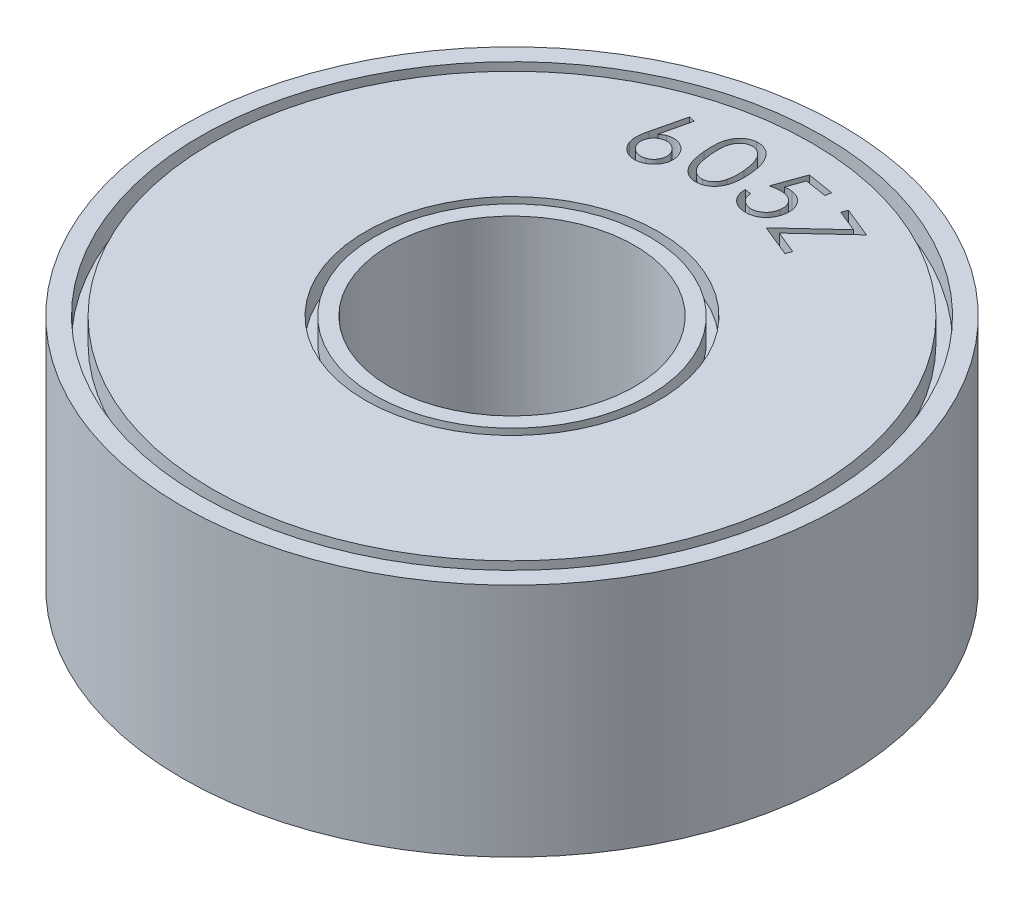
from build123d import *

# Parameters (mm, degrees)
SKETCH1_R           = 7
SKETCH1_R_2         = 2.6
BOSS_EXTRUDE1_DEPTH = 5
SKETCH2_R           = 3.107412226
SKETCH2_R_2         = 2.917242266
CUT_EXTRUDE1_DEPTH  = 0.5
SKETCH3_R           = 6.614287506
SKETCH3_R_2         = 6.365008751
CUT_EXTRUDE2_DEPTH  = 0.5
CUT_EXTRUDE3_DEPTH  = 0.5
SKETCH7_R           = 6.648627536
SKETCH7_R_2         = 6.469556806
SKETCH7_R_3         = 3.047068381
SKETCH7_R_4         = 2.824964769
CUT_EXTRUDE4_DEPTH  = 0.5
CUT_EXTRUDE5_DEPTH  = 0.5


with BuildPart() as part:
    # Sketch1 → Boss-Extrude1 (new body)
    with BuildSketch(Plane(origin=(0, 0, 0), x_dir=(1, 0, 0), z_dir=(0, 1, 0))):
        with Locations(Location((0, 0, 0), (0, 0, 270))):
            Circle(SKETCH1_R)
        with Locations(Location((0, 0, 0), (0, 0, 270))):
            Circle(SKETCH1_R_2, mode=Mode.SUBTRACT)
    extrude(amount=BOSS_EXTRUDE1_DEPTH)

    # Sketch2 → Cut-Extrude1 (cut)
    with BuildSketch(Plane(origin=(0, 5, 0), x_dir=(1, 0, 0), z_dir=(0, 1, 0))):
        with Locations(Location((0, 0, 0), (0, 0, 270))):
            Circle(SKETCH2_R)
        with Locations(Location((0, 0, 0), (0, 0, 270))):
            Circle(SKETCH2_R_2, mode=Mode.SUBTRACT)
    extrude(amount=-CUT_EXTRUDE1_DEPTH, mode=Mode.SUBTRACT)

    # Sketch3 → Cut-Extrude2 (cut)
    with BuildSketch(Plane(origin=(0, 5, 0), x_dir=(1, 0, 0), z_dir=(0, 1, 0))):
        with Locations(Location((0, 0, 0), (0, 0, 270))):
            Circle(SKETCH3_R)
        with Locations(Location((0, 0, 0), (0, 0, 270))):
            Circle(SKETCH3_R_2, mode=Mode.SUBTRACT)
    extrude(amount=-CUT_EXTRUDE2_DEPTH, mode=Mode.SUBTRACT)

    # Sketch5 → Cut-Extrude3 (cut)
    with BuildSketch(Plane(origin=(0, 5, 0), x_dir=(1, 0, 0), z_dir=(0, 1, 0))):
        with BuildLine():
            Line((-1.77464756, 5.546064141), (-1.648769071, 5.517178341))
            Line((-1.648769071, 5.517178341), (-1.794788118, 4.890965984))
            add(Edge.make_bspline(
                [(-1.794788118, 4.890965984), (-1.785096073, 4.898458099), (-1.766189956, 4.913072848), (-1.736665853, 4.931761196), (-1.707427507, 4.947854783), (-1.687285201, 4.9559104), (-1.677389864, 4.959867894)],
                knots=[0, 0, 0, 0, 1.074983439, 2.096953016, 3.065087646, 4, 4, 4, 4], degree=3))
            add(Edge.make_bspline(
                [(-1.677389864, 4.959867894), (-1.665275584, 4.964019421), (-1.641449235, 4.972184638), (-1.604872801, 4.979723444), (-1.568588417, 4.983796753), (-1.532418517, 4.984158001), (-1.496378982, 4.980279861), (-1.460457571, 4.972930764), (-1.424834929, 4.961338909), (-1.389812824, 4.946313678), (-1.356125763, 4.928119279), (-1.324370957, 4.907327131), (-1.295679138, 4.883129899), (-1.269261033, 4.856721626), (-1.24590325, 4.8272106), (-1.224814398, 4.795293225), (-1.206433444, 4.760488564), (-1.196617452, 4.735771442), (-1.191631401, 4.723216335)],
                knots=[0, 0, 0, 0, 1.020154289, 2.006438123, 2.970106571, 3.927992439, 4.883908413, 5.854961009, 6.846136469, 7.86526912, 8.889427122, 9.895430617, 10.885579588, 11.87665495, 12.868805842, 13.880684614, 14.923489853, 16, 16, 16, 16], degree=3))
            add(Edge.make_bspline(
                [(-1.191631401, 4.723216335), (-1.185763997, 4.705677489), (-1.174231565, 4.671204739), (-1.16536594, 4.617909511), (-1.163378909, 4.564984654), (-1.168718636, 4.51273181), (-1.180965661, 4.461942206), (-1.199840731, 4.41310195), (-1.226271738, 4.367045113), (-1.258666864, 4.32379223), (-1.29660493, 4.28474739), (-1.339171993, 4.251149774), (-1.385599916, 4.22271722), (-1.419232295, 4.208920841), (-1.43623318, 4.201946887)],
                knots=[0, 0, 0, 0, 1.035512558, 2.035308643, 3.016484276, 3.997109838, 4.970052175, 5.937534324, 6.922203205, 7.93743261, 8.960063542, 9.96475378, 10.971200086, 12, 12, 12, 12], degree=3))
            add(Edge.make_bspline(
                [(-1.43623318, 4.201946887), (-1.453069731, 4.196349022), (-1.486328625, 4.18529101), (-1.538132233, 4.177075568), (-1.590209072, 4.17507396), (-1.642272632, 4.180121209), (-1.693185104, 4.19200707), (-1.741823995, 4.210665009), (-1.78756302, 4.236127091), (-1.829741861, 4.267944116), (-1.867829416, 4.304857265), (-1.900548991, 4.346263197), (-1.928197584, 4.391352218), (-1.941510188, 4.423986908), (-1.948227371, 4.440453498)],
                knots=[0, 0, 0, 0, 1.013740106, 2.002540567, 2.98876705, 3.989087606, 4.985813625, 5.971392323, 6.960102356, 7.970965595, 8.986065581, 9.986181813, 10.983881298, 12, 12, 12, 12], degree=3))
            add(Edge.make_bspline(
                [(-1.948227371, 4.440453498), (-1.952555425, 4.45336504), (-1.961336427, 4.479560707), (-1.96978437, 4.521095857), (-1.975460254, 4.564748639), (-1.976913266, 4.602895327), (-1.97619598, 4.635077867), (-1.974566121, 4.661151722), (-1.971961923, 4.688923168), (-1.9678103, 4.718128126), (-1.963147279, 4.749098068), (-1.957025936, 4.781619659), (-1.949483101, 4.815748189), (-1.944095701, 4.839029234), (-1.94133718, 4.850949875)],
                knots=[0, 0, 0, 0, 1.175268312, 2.384450834, 3.653583733, 4.974682368, 5.67682338, 6.433595722, 7.230792766, 8.085439344, 8.981130992, 9.935908238, 10.943118889, 12, 12, 12, 12], degree=3))
            Line((-1.94133718, 4.850949875), (-1.77464756, 5.546064141))
        make_face()
        with BuildLine():
            add(Edge.make_bspline(
                [(-1.66678957, 4.841144603), (-1.675432998, 4.837689072), (-1.692559368, 4.83084217), (-1.716598923, 4.81781237), (-1.738850711, 4.802791065), (-1.759373562, 4.785926814), (-1.777627034, 4.766544045), (-1.794474921, 4.745711209), (-1.809064257, 4.722566186), (-1.821932712, 4.697974042), (-1.832525016, 4.672270155), (-1.840114084, 4.64601945), (-1.84577111, 4.619746751), (-1.847555861, 4.59313258), (-1.847552339, 4.566500973), (-1.844144539, 4.539801039), (-1.838408479, 4.5128864), (-1.832505281, 4.495260711), (-1.82950408, 4.486299768)],
                knots=[0, 0, 0, 0, 1.028577375, 2.038056822, 3.015999467, 3.993942112, 4.967974926, 5.954899733, 6.95197029, 7.987342216, 9.021192721, 10.019410766, 11.005900495, 11.985743526, 12.962514865, 13.946244635, 14.955865826, 16, 16, 16, 16], degree=3))
            add(Edge.make_bspline(
                [(-1.82950408, 4.486299768), (-1.826048549, 4.477656341), (-1.819201647, 4.460529971), (-1.806171847, 4.436490416), (-1.791150541, 4.414238628), (-1.774286291, 4.393715776), (-1.754903522, 4.375462306), (-1.734070687, 4.358614411), (-1.710925662, 4.344025106), (-1.686333522, 4.331156531), (-1.660629623, 4.320564671), (-1.634378961, 4.312974009), (-1.608192387, 4.307341368), (-1.581669454, 4.30552229), (-1.555126027, 4.305543969), (-1.528508398, 4.308917039), (-1.501773254, 4.314685766), (-1.484326544, 4.32058519), (-1.475454267, 4.323585258)],
                knots=[0, 0, 0, 0, 1.030418755, 2.041705391, 3.021398769, 4.001092146, 4.976868692, 5.965560311, 6.964415844, 8.001641312, 9.037342637, 10.037347711, 11.025603474, 11.997447403, 12.975967378, 13.96145824, 14.963328506, 16, 16, 16, 16], degree=3))
            add(Edge.make_bspline(
                [(-1.475454267, 4.323585258), (-1.466705766, 4.32700987), (-1.449518125, 4.333737995), (-1.425590086, 4.347107914), (-1.403132662, 4.361720393), (-1.38299218, 4.37902272), (-1.364193363, 4.397707948), (-1.347887476, 4.418969603), (-1.332787338, 4.441715771), (-1.320401516, 4.466587551), (-1.30964518, 4.492251698), (-1.302146693, 4.518637162), (-1.296609509, 4.544909262), (-1.294221462, 4.571407636), (-1.294821472, 4.597962542), (-1.298038022, 4.624580792), (-1.303849043, 4.651316123), (-1.309742648, 4.668762808), (-1.312739757, 4.677635071)],
                knots=[0, 0, 0, 0, 1.039051435, 2.041360351, 3.028812302, 4.000639027, 4.975856113, 5.958111039, 6.961898324, 7.994252835, 9.02956857, 10.038584196, 11.026472033, 11.998790847, 12.977093218, 13.962217185, 14.963714457, 16, 16, 16, 16], degree=3))
            add(Edge.make_bspline(
                [(-1.312739757, 4.677635071), (-1.316179921, 4.686374706), (-1.322967077, 4.703617273), (-1.336165659, 4.727734109), (-1.350984461, 4.750218571), (-1.368075105, 4.770714672), (-1.387139748, 4.789326121), (-1.408371857, 4.805749132), (-1.431140547, 4.820825574), (-1.456003858, 4.833225871), (-1.481600274, 4.843916135), (-1.507866672, 4.851519868), (-1.53406513, 4.856995741), (-1.56056444, 4.859424893), (-1.587096227, 4.858703179), (-1.613756326, 4.855941614), (-1.6404677, 4.850009787), (-1.657916321, 4.844133106), (-1.66678957, 4.841144603)],
                knots=[0, 0, 0, 0, 1.038234345, 2.048349523, 3.035024961, 4.013583476, 4.995017316, 5.976499817, 6.979497743, 8.011040432, 9.045542016, 10.044388699, 11.031499681, 12.003053883, 12.980586937, 13.963819656, 14.964529371, 16, 16, 16, 16], degree=3))
        make_face(mode=Mode.SUBTRACT)
        with BuildLine():
            add(Edge.make_bspline(
                [(-0.986592206, 5.067066278), (-0.988405517, 5.08816878), (-0.991922584, 5.129098826), (-0.994830361, 5.18893886), (-0.99568949, 5.245242381), (-0.994482554, 5.298033199), (-0.990960664, 5.347180076), (-0.985962819, 5.39289328), (-0.978134053, 5.435054616), (-0.968798981, 5.474096316), (-0.956721509, 5.510083321), (-0.944001545, 5.544150393), (-0.929077602, 5.575979261), (-0.912561462, 5.6057805), (-0.894659432, 5.633779016), (-0.874576009, 5.659392902), (-0.853464208, 5.683518684), (-0.830332972, 5.70516311), (-0.805956552, 5.72467695), (-0.780783746, 5.74238274), (-0.754415082, 5.757386548), (-0.727329931, 5.77057498), (-0.699068392, 5.781128909), (-0.669833797, 5.789593351), (-0.639650584, 5.796117592), (-0.619054064, 5.798398853), (-0.608691732, 5.79954658)],
                knots=[0, 0, 0, 0, 1.644809883, 3.190244655, 4.651655908, 6.017307418, 7.28961207, 8.477552208, 9.586351613, 10.617970442, 11.592075519, 12.532351563, 13.440830871, 14.319069932, 15.177278937, 16.01845527, 16.844557458, 17.66474179, 18.474734591, 19.268320699, 20.052030048, 20.828347882, 21.605604854, 22.391533073, 23.190762926, 24, 24, 24, 24], degree=3))
            add(Edge.make_bspline(
                [(-0.608691732, 5.79954658), (-0.598187027, 5.800323587), (-0.577282375, 5.801869852), (-0.54606043, 5.801366106), (-0.515357616, 5.797989189), (-0.485191239, 5.79285449), (-0.455610185, 5.785056332), (-0.426500698, 5.774972801), (-0.39806028, 5.762190102), (-0.370087092, 5.747358303), (-0.343048552, 5.730098341), (-0.316918719, 5.710427398), (-0.292152609, 5.688130786), (-0.268325707, 5.663592234), (-0.245908844, 5.636451477), (-0.224279608, 5.607026803), (-0.204375327, 5.57484862), (-0.185039179, 5.540523718), (-0.167201701, 5.50322229), (-0.151090504, 5.462559348), (-0.136657363, 5.418626589), (-0.123602991, 5.371415898), (-0.112247787, 5.320922779), (-0.102913564, 5.266929577), (-0.094561085, 5.209774182), (-0.090541955, 5.170437199), (-0.088482313, 5.150278585)],
                knots=[0, 0, 0, 0, 0.812180823, 1.616262325, 2.404042693, 3.19261816, 3.974275905, 4.760758835, 5.565994135, 6.376773437, 7.200841365, 8.037515538, 8.89642022, 9.768545579, 10.673172549, 11.609396373, 12.582931568, 13.589475693, 14.646938443, 15.769165122, 16.960630792, 18.211937759, 19.545843377, 20.95051789, 22.437263645, 24, 24, 24, 24], degree=3))
            add(Edge.make_bspline(
                [(-0.088482313, 5.150278585), (-0.086718711, 5.130149191), (-0.083280361, 5.090904566), (-0.081150173, 5.033430578), (-0.080327749, 4.978893982), (-0.082231683, 4.927340193), (-0.086129592, 4.878784806), (-0.092113531, 4.83318633), (-0.100600815, 4.790646402), (-0.110997939, 4.750840701), (-0.123086248, 4.713611329), (-0.137404835, 4.67883355), (-0.15246791, 4.645836287), (-0.169946919, 4.615261347), (-0.188684085, 4.586587823), (-0.209040003, 4.55999301), (-0.231279282, 4.535789537), (-0.254701569, 4.51347301), (-0.2797379, 4.493742672), (-0.305418064, 4.475749664), (-0.332323281, 4.460494027), (-0.360000466, 4.446981602), (-0.388803989, 4.436266038), (-0.418492042, 4.427737442), (-0.449046196, 4.421268089), (-0.469891665, 4.418787241), (-0.480428177, 4.417533275)],
                knots=[0, 0, 0, 0, 1.560019437, 3.041441778, 4.439806569, 5.770751862, 7.023175031, 8.200063667, 9.319720786, 10.37028258, 11.375444132, 12.3393508, 13.27310108, 14.174140243, 15.055735392, 15.916610614, 16.75672562, 17.591479347, 18.411727224, 19.215849523, 20.010279916, 20.797385231, 21.591727773, 22.379689713, 23.181000944, 24, 24, 24, 24], degree=3))
            add(Edge.make_bspline(
                [(-0.480428177, 4.417533275), (-0.490846105, 4.416715793), (-0.511490833, 4.415095826), (-0.542241203, 4.416173667), (-0.572466097, 4.418946021), (-0.60202656, 4.424352311), (-0.6311886, 4.431639762), (-0.659514019, 4.441929323), (-0.687485449, 4.454070877), (-0.714774614, 4.468696931), (-0.741288509, 4.485562588), (-0.766436515, 4.50503044), (-0.790555232, 4.526626331), (-0.813192587, 4.55083673), (-0.835038518, 4.577153355), (-0.855722282, 4.605802764), (-0.875066191, 4.636902629), (-0.893205614, 4.670621463), (-0.910258882, 4.707248002), (-0.925653379, 4.747535897), (-0.939312148, 4.791669775), (-0.95162656, 4.839543346), (-0.962835528, 4.891055097), (-0.972205553, 4.946348682), (-0.980536776, 5.005364331), (-0.984535848, 5.046112966), (-0.986592206, 5.067066278)],
                knots=[0, 0, 0, 0, 0.811819082, 1.608744364, 2.388468332, 3.16982384, 3.942712656, 4.722527355, 5.509806294, 6.311717109, 7.127101459, 7.949913989, 8.781479029, 9.641374982, 10.524221401, 11.439154072, 12.386256276, 13.369568315, 14.41427916, 15.525178722, 16.719851279, 18.004138739, 19.367348028, 20.817077663, 22.363312919, 24, 24, 24, 24], degree=3))
        make_face()
        with BuildLine():
            add(Edge.make_bspline(
                [(-0.861773746, 5.076076528), (-0.860034501, 5.058042856), (-0.856669996, 5.023157399), (-0.849898353, 4.97272846), (-0.842656906, 4.925756881), (-0.834137475, 4.882380695), (-0.825006669, 4.842447212), (-0.814608295, 4.806142032), (-0.803679419, 4.773116456), (-0.791256022, 4.743503106), (-0.778349902, 4.716357346), (-0.763772911, 4.69172033), (-0.748818833, 4.668536566), (-0.732589575, 4.647290825), (-0.715372738, 4.627822882), (-0.696930897, 4.610412953), (-0.677958666, 4.594188695), (-0.650961225, 4.576396311), (-0.616638646, 4.557633897), (-0.573699282, 4.543092131), (-0.530375994, 4.53484129), (-0.501482035, 4.536138698), (-0.48705336, 4.536786581)],
                knots=[0, 0, 0, 0, 1.481038001, 2.865012089, 4.15917067, 5.365885815, 6.478258119, 7.506956557, 8.452436816, 9.320168659, 10.130881019, 10.907521234, 11.658660638, 12.385199366, 13.091093666, 13.780655211, 14.457506438, 15.128514792, 16.420798057, 17.642653434, 18.822820111, 20, 20, 20, 20], degree=3))
            add(Edge.make_bspline(
                [(-0.48705336, 4.536786581), (-0.472716343, 4.538849284), (-0.444130437, 4.542962012), (-0.40294404, 4.55819322), (-0.363896239, 4.580111116), (-0.333936262, 4.604177068), (-0.311485928, 4.626547887), (-0.295627577, 4.645285823), (-0.281187577, 4.665877724), (-0.268433816, 4.688214011), (-0.256128715, 4.711872951), (-0.246160566, 4.737700231), (-0.236611605, 4.76490115), (-0.231876563, 4.783904941), (-0.229466221, 4.793578698)],
                knots=[0, 0, 0, 0, 1.336060631, 2.663908518, 4.03149843, 5.461320918, 6.200520743, 6.959707959, 7.727804488, 8.522029534, 9.336529577, 10.190370498, 11.078819832, 12, 12, 12, 12], degree=3))
            add(Edge.make_bspline(
                [(-0.229466221, 4.793578698), (-0.226579221, 4.805915681), (-0.220713244, 4.830982699), (-0.214572728, 4.869786025), (-0.209777915, 4.910183575), (-0.206571393, 4.952179083), (-0.205371721, 4.995859008), (-0.205577011, 5.041206399), (-0.207739339, 5.088229892), (-0.210373931, 5.120074943), (-0.211710729, 5.136233195)],
                knots=[0, 0, 0, 0, 0.881959968, 1.792018815, 2.733462538, 3.714210099, 4.723398733, 5.775191773, 6.87112714, 8, 8, 8, 8], degree=3))
            add(Edge.make_bspline(
                [(-0.211710729, 5.136233195), (-0.21328037, 5.152410452), (-0.216348531, 5.184031971), (-0.222661172, 5.230099309), (-0.230543888, 5.273692474), (-0.238792266, 5.315055022), (-0.248589929, 5.354062823), (-0.259740382, 5.390645457), (-0.271883939, 5.424893965), (-0.285154987, 5.456831814), (-0.299457725, 5.486433365), (-0.314434828, 5.51393095), (-0.330872715, 5.538789702), (-0.347316728, 5.562056719), (-0.365158586, 5.582710304), (-0.383798868, 5.601218573), (-0.403425055, 5.617297732), (-0.429932661, 5.635884186), (-0.464334579, 5.653883046), (-0.506658757, 5.668951342), (-0.549710806, 5.676208622), (-0.578286758, 5.675043633), (-0.592526284, 5.674463113)],
                knots=[0, 0, 0, 0, 1.329646321, 2.599046225, 3.802658319, 4.95354198, 6.049043318, 7.09153349, 8.081313068, 9.020820353, 9.919410277, 10.770170308, 11.580011283, 12.356297843, 13.099412652, 13.809755219, 14.502829676, 15.172447414, 16.455882401, 17.664949743, 18.836433918, 20, 20, 20, 20], degree=3))
            add(Edge.make_bspline(
                [(-0.592526284, 5.674463113), (-0.606942314, 5.672385418), (-0.635682535, 5.668243264), (-0.677271153, 5.653240073), (-0.716185853, 5.630356002), (-0.746684393, 5.60636804), (-0.769329221, 5.583727392), (-0.785364775, 5.56481347), (-0.799812153, 5.544127106), (-0.813174932, 5.521903261), (-0.825416603, 5.498166619), (-0.835849787, 5.47251684), (-0.845549518, 5.445548513), (-0.853452709, 5.416556329), (-0.860230676, 5.385185521), (-0.865107924, 5.350732891), (-0.868516961, 5.312966123), (-0.87028139, 5.271936874), (-0.870524543, 5.227650019), (-0.869017473, 5.180115416), (-0.866563749, 5.129192417), (-0.863405971, 5.094176114), (-0.861773746, 5.076076528)],
                knots=[0, 0, 0, 0, 1.188628619, 2.369684876, 3.586225843, 4.86646694, 5.530378326, 6.201751162, 6.891065185, 7.590893375, 8.320892274, 9.072022264, 9.853244675, 10.662798496, 11.526895042, 12.475782571, 13.505652775, 14.62626638, 15.83242943, 17.12574396, 18.51432504, 20, 20, 20, 20], degree=3))
        make_face(mode=Mode.SUBTRACT)
        with BuildLine():
            Line((1.125972477, 5.661253546), (1.106361934, 5.537230108))
            Line((1.106361934, 5.537230108), (0.642069065, 5.61090215))
            Line((0.642069065, 5.61090215), (0.520960708, 5.265862587))
            add(Edge.make_bspline(
                [(0.520960708, 5.265862587), (0.535343971, 5.267484323), (0.563170685, 5.270621831), (0.603903619, 5.271782477), (0.64201574, 5.270805066), (0.666377926, 5.267647965), (0.678110064, 5.266127594)],
                knots=[0, 0, 0, 0, 1.101444241, 2.130919383, 3.099903783, 4, 4, 4, 4], degree=3))
            add(Edge.make_bspline(
                [(0.678110064, 5.266127594), (0.69257013, 5.263483678), (0.721004781, 5.258284612), (0.761920056, 5.245969055), (0.800354011, 5.23027565), (0.836306043, 5.211201585), (0.869518595, 5.188506791), (0.900373588, 5.162699718), (0.928125929, 5.132996072), (0.953481423, 5.100586798), (0.975711713, 5.065773304), (0.994109436, 5.029008045), (1.008491645, 4.990635083), (1.018848134, 4.950748306), (1.025119719, 4.909365068), (1.027875013, 4.866528064), (1.026178309, 4.822079024), (1.02224288, 4.792181419), (1.020234546, 4.776924035)],
                knots=[0, 0, 0, 0, 1.053815571, 2.072250396, 3.058335495, 4.027830679, 4.985680291, 5.938991898, 6.907181616, 7.895869278, 8.887294429, 9.86495549, 10.839469665, 11.821556223, 12.815428567, 13.837582294, 14.896472219, 16, 16, 16, 16], degree=3))
            add(Edge.make_bspline(
                [(1.020234546, 4.776924035), (1.018323631, 4.766386501), (1.014527536, 4.745453345), (1.006754128, 4.714768681), (0.997591963, 4.684837405), (0.986086143, 4.656073077), (0.973122764, 4.628178182), (0.958461266, 4.601251976), (0.94207478, 4.57525549), (0.923770232, 4.550498976), (0.904324512, 4.526944531), (0.883499221, 4.505190327), (0.861931833, 4.484934646), (0.838777874, 4.466874503), (0.814943897, 4.450173702), (0.78970821, 4.435508467), (0.76359294, 4.422579487), (0.736430333, 4.411352712), (0.708407477, 4.40219696), (0.679684772, 4.39461789), (0.650240698, 4.389447582), (0.62015434, 4.385952931), (0.589352049, 4.384414186), (0.557842706, 4.384621606), (0.525630248, 4.387053485), (0.504074437, 4.390071648), (0.493134937, 4.391603355)],
                knots=[0, 0, 0, 0, 1.053663813, 2.0931378, 3.113236906, 4.131890297, 5.139203412, 6.138985671, 7.147123746, 8.160831377, 9.167056011, 10.150912663, 11.122867697, 12.075978519, 13.038164913, 13.984950897, 14.94525034, 15.904210948, 16.874648547, 17.844579808, 18.825089279, 19.813926352, 20.823712324, 21.858267034, 22.913077848, 24, 24, 24, 24], degree=3))
            add(Edge.make_bspline(
                [(0.493134937, 4.391603355), (0.480182866, 4.393923545), (0.454728762, 4.398483306), (0.418017431, 4.409368906), (0.383261331, 4.42242937), (0.35057863, 4.438593389), (0.319782682, 4.45722738), (0.291332576, 4.479269847), (0.264742057, 4.503660327), (0.240318063, 4.530642877), (0.218883359, 4.559953095), (0.199810604, 4.590599709), (0.183855182, 4.622699353), (0.171226137, 4.656223269), (0.161192582, 4.690921364), (0.154759574, 4.727072934), (0.150890742, 4.764558108), (0.150794363, 4.789988085), (0.150745447, 4.802894755)],
                knots=[0, 0, 0, 0, 1.074273637, 2.111220172, 3.123177597, 4.104377325, 5.085922037, 6.058832229, 7.039500976, 8.03084039, 9.026818808, 10.002215248, 10.976943965, 11.950041514, 12.92551805, 13.92348174, 14.946088947, 16, 16, 16, 16], degree=3))
            Line((0.150745447, 4.802894755), (0.284309149, 4.781694167))
            add(Edge.make_bspline(
                [(0.284309149, 4.781694167), (0.285090291, 4.769205121), (0.286590314, 4.745222477), (0.293252376, 4.710918894), (0.302098668, 4.679482217), (0.315205301, 4.651183476), (0.331294507, 4.62534004), (0.350840084, 4.601684831), (0.373636449, 4.579773312), (0.39939135, 4.559878395), (0.427432572, 4.542374851), (0.457384226, 4.528759223), (0.488235063, 4.517673066), (0.50966812, 4.513664551), (0.520430694, 4.511651683)],
                knots=[0, 0, 0, 0, 1.150191904, 2.208706785, 3.209112183, 4.147501009, 5.067654532, 6.003258345, 6.963223747, 7.971227645, 8.993063868, 9.996732811, 10.994062728, 12, 12, 12, 12], degree=3))
            add(Edge.make_bspline(
                [(0.520430694, 4.511651683), (0.531013519, 4.510277705), (0.551942628, 4.50756046), (0.58330479, 4.507456479), (0.613994011, 4.51019025), (0.643847107, 4.516827017), (0.673252888, 4.525998414), (0.701889905, 4.538857682), (0.72987193, 4.554925984), (0.756942793, 4.573875004), (0.782453409, 4.595296315), (0.805418172, 4.619190935), (0.826010188, 4.644841832), (0.843409449, 4.672951671), (0.858621277, 4.702679743), (0.871184867, 4.734406924), (0.880660758, 4.768205266), (0.884995608, 4.791549136), (0.887200859, 4.803424769)],
                knots=[0, 0, 0, 0, 0.980344137, 1.938776094, 2.877070754, 3.807386993, 4.744943156, 5.704853778, 6.68708022, 7.707775255, 8.739398813, 9.744594323, 10.750478673, 11.757772031, 12.778467065, 13.817640471, 14.889776961, 16, 16, 16, 16], degree=3))
            add(Edge.make_bspline(
                [(0.887200859, 4.803424769), (0.888615076, 4.814184521), (0.891389004, 4.83528933), (0.892457854, 4.866694492), (0.890637473, 4.897046825), (0.885930828, 4.926288913), (0.878104636, 4.954300049), (0.867775982, 4.981260398), (0.854496112, 5.007066493), (0.838234901, 5.031360747), (0.819846716, 5.054141064), (0.79894659, 5.074750644), (0.775879079, 5.092964778), (0.750739387, 5.109090102), (0.723321744, 5.122572821), (0.693711757, 5.133608297), (0.662117439, 5.142803375), (0.640082911, 5.14672472), (0.628818698, 5.14872934)],
                knots=[0, 0, 0, 0, 1.071838228, 2.102366613, 3.099264358, 4.072144398, 5.022925944, 5.967920769, 6.920423477, 7.883900448, 8.851755896, 9.808408615, 10.777601261, 11.750951026, 12.754133603, 13.790007757, 14.870235752, 16, 16, 16, 16], degree=3))
            add(Edge.make_bspline(
                [(0.628818698, 5.14872934), (0.618940771, 5.150127549), (0.59854796, 5.153014129), (0.566819027, 5.154279831), (0.533288332, 5.154131299), (0.497918201, 5.151551855), (0.460608107, 5.147320641), (0.421453649, 5.141167035), (0.380407018, 5.133251071), (0.352654671, 5.126498929), (0.338370648, 5.123023628)],
                knots=[0, 0, 0, 0, 0.815470422, 1.683524807, 2.593873392, 3.556964145, 4.582193149, 5.664292602, 6.797820571, 8, 8, 8, 8], degree=3))
            Line((0.338370648, 5.123023628), (0.561506832, 5.750826028))
            Line((0.561506832, 5.750826028), (1.125972477, 5.661253546))
        make_face()
        Polygon((1.579849833, 5.39926149), (1.62808117, 5.516924751), (2.270723982, 5.25456748), (1.312192415, 4.362817763), (1.79583082, 4.165387291), (1.747599483, 4.046929008), (1.07607087, 4.32121161), (2.037782526, 5.212431312), align=None)
    extrude(amount=-CUT_EXTRUDE3_DEPTH, mode=Mode.SUBTRACT)

    # Sketch7 → Cut-Extrude4 (cut)
    with BuildSketch(Plane.XZ):
        with Locations(Location((0, 0, 0), (0, 0, 270))):
            Circle(SKETCH7_R)
        with Locations(Location((0, 0, 0), (0, 0, 270))):
            Circle(SKETCH7_R_2, mode=Mode.SUBTRACT)
        with Locations(Location((0, 0, 0), (0, 0, 270))):
            Circle(SKETCH7_R_3)
        with Locations(Location((0, 0, 0), (0, 0, 270))):
            Circle(SKETCH7_R_4, mode=Mode.SUBTRACT)
    extrude(amount=-CUT_EXTRUDE4_DEPTH, mode=Mode.SUBTRACT)

    # Sketch8 → Cut-Extrude5 (cut)
    with BuildSketch(Plane(origin=(0, 0, 0), x_dir=(-1, 0, 0), z_dir=(0, -1, 0))):
        with BuildLine():
            Line((1.774387898, -5.470384158), (1.647449379, -5.445738475))
            Line((1.647449379, -5.445738475), (1.772797854, -4.812900934))
            add(Edge.make_bspline(
                [(1.772797854, -4.812900934), (1.763369719, -4.820731629), (1.74500262, -4.835986729), (1.716205087, -4.855922322), (1.687378561, -4.87284505), (1.667499797, -4.88171033), (1.657784666, -4.886042962)],
                knots=[0, 0, 0, 0, 1.074211897, 2.092689257, 3.067860925, 4, 4, 4, 4], degree=3))
            add(Edge.make_bspline(
                [(1.657784666, -4.886042962), (1.645766887, -4.890631073), (1.622170213, -4.899639739), (1.585691623, -4.908555741), (1.549405422, -4.914018609), (1.513063647, -4.915246717), (1.476806162, -4.912958083), (1.440613324, -4.906408444), (1.404355521, -4.896350115), (1.368695235, -4.882264897), (1.33414169, -4.865314129), (1.30186986, -4.844992938), (1.272114141, -4.821929404), (1.244965194, -4.796001212), (1.2201154, -4.767565886), (1.198085646, -4.736082265), (1.178650443, -4.701777335), (1.167931079, -4.677406531), (1.162485938, -4.665026836)],
                knots=[0, 0, 0, 0, 1.020693353, 2.004111539, 2.975369488, 3.93006982, 4.886212375, 5.855009802, 6.845607774, 7.869550409, 8.895437675, 9.897814049, 10.892699968, 11.880138289, 12.874653153, 13.88670369, 14.926503864, 16, 16, 16, 16], degree=3))
            add(Edge.make_bspline(
                [(1.162485938, -4.665026836), (1.155969422, -4.647688389), (1.143134702, -4.613539147), (1.132924986, -4.56041642), (1.128905632, -4.507547804), (1.132414842, -4.455006899), (1.142983019, -4.403544531), (1.160637563, -4.354030456), (1.185379171, -4.30693303), (1.216640526, -4.262744539), (1.253058815, -4.222060877), (1.294721119, -4.186817577), (1.34031474, -4.156652858), (1.373638405, -4.141723186), (1.390392255, -4.134217124)],
                knots=[0, 0, 0, 0, 1.033631247, 2.035806516, 3.010908285, 3.990599145, 4.968584082, 5.938371495, 6.918895558, 7.932522835, 8.956784215, 9.961971142, 10.975357897, 12, 12, 12, 12], degree=3))
            add(Edge.make_bspline(
                [(1.390392255, -4.134217124), (1.407042174, -4.128116831), (1.440044009, -4.116025429), (1.491629765, -4.105843512), (1.543828408, -4.10229142), (1.596112263, -4.105852477), (1.64759305, -4.115753706), (1.697005906, -4.132766225), (1.743566145, -4.157087089), (1.787126177, -4.187451607), (1.826538812, -4.223288596), (1.861251603, -4.263408959), (1.890168578, -4.307847868), (1.904650522, -4.340092535), (1.91192671, -4.356293279)],
                knots=[0, 0, 0, 0, 1.010135966, 2.002192258, 2.986851559, 3.986592941, 4.982607515, 5.968902517, 6.955905053, 7.969227535, 8.989366082, 9.986157692, 10.988181708, 12, 12, 12, 12], degree=3))
            add(Edge.make_bspline(
                [(1.91192671, -4.356293279), (1.916670986, -4.369023565), (1.926348548, -4.394991306), (1.936602838, -4.436280158), (1.942974226, -4.480132829), (1.945959993, -4.518337825), (1.946300761, -4.550639177), (1.945363206, -4.576792593), (1.943936817, -4.60465548), (1.940864315, -4.634068983), (1.936880962, -4.665170727), (1.931829739, -4.697950695), (1.925748937, -4.732413643), (1.920989797, -4.755846195), (1.918551894, -4.767849686)],
                knots=[0, 0, 0, 0, 1.169804562, 2.386213675, 3.656292896, 4.984226008, 5.684441463, 6.43823553, 7.238650877, 8.087564122, 8.985290963, 9.940017916, 10.94475966, 12, 12, 12, 12], degree=3))
            Line((1.918551894, -4.767849686), (1.774387898, -5.470384158))
        make_face()
        with BuildLine():
            add(Edge.make_bspline(
                [(1.642944255, -4.767584678), (1.65151376, -4.763877641), (1.668447838, -4.756552215), (1.69202748, -4.742555791), (1.713974059, -4.726921062), (1.733868182, -4.709135002), (1.751715964, -4.689344248), (1.767747007, -4.667726442), (1.781809431, -4.644123639), (1.793535524, -4.618732827), (1.803400241, -4.592582289), (1.810273988, -4.565909493), (1.814549645, -4.539295697), (1.816257132, -4.512653359), (1.81478007, -4.485931776), (1.810909912, -4.459178207), (1.803891565, -4.432396799), (1.797336615, -4.414982874), (1.793998441, -4.40611466)],
                knots=[0, 0, 0, 0, 1.027336611, 2.030105507, 3.012855138, 3.991213271, 4.962338052, 5.942966777, 6.950678349, 7.982106211, 9.019389827, 10.024562487, 11.009764728, 11.98434297, 12.95838697, 13.951720843, 14.956893503, 16, 16, 16, 16], degree=3))
            add(Edge.make_bspline(
                [(1.793998441, -4.40611466), (1.790291403, -4.397545155), (1.782965977, -4.380611076), (1.768969555, -4.357031433), (1.753334823, -4.335084863), (1.735548773, -4.315190705), (1.715757984, -4.297343055), (1.694140308, -4.281311508), (1.670537, -4.267251034), (1.64514813, -4.255517442), (1.619070442, -4.245710822), (1.592510625, -4.238745558), (1.566059169, -4.234530146), (1.539512138, -4.232806575), (1.512953939, -4.234236203), (1.48634982, -4.238271127), (1.459634294, -4.244773986), (1.442358555, -4.251421053), (1.433588452, -4.254795466)],
                knots=[0, 0, 0, 0, 1.029931187, 2.035232613, 3.020464214, 4.001293226, 4.974870619, 5.957975957, 6.968232542, 8.002265313, 9.042168627, 10.04044387, 11.028134275, 11.995438678, 12.971942662, 13.958139231, 14.963440656, 16, 16, 16, 16], degree=3))
            add(Edge.make_bspline(
                [(1.433588452, -4.254795466), (1.425018947, -4.258502504), (1.408084868, -4.26582793), (1.384505226, -4.279824352), (1.362558652, -4.295459084), (1.342664509, -4.313245135), (1.324816801, -4.333035921), (1.308785476, -4.354653605), (1.294724146, -4.378256883), (1.282993842, -4.403645867), (1.273174995, -4.429723132), (1.266253494, -4.456284464), (1.261879748, -4.482725568), (1.260738466, -4.509283808), (1.261586191, -4.535846844), (1.265778924, -4.562443282), (1.272238898, -4.589159823), (1.278891856, -4.606435423), (1.282269258, -4.615205455)],
                knots=[0, 0, 0, 0, 1.029994237, 2.035357204, 3.020649118, 4.001538174, 4.975175166, 5.958340687, 6.968659117, 8.002755189, 9.042722162, 10.041058517, 11.028809386, 11.995631987, 12.971757293, 13.958014234, 14.963377201, 16, 16, 16, 16], degree=3))
            add(Edge.make_bspline(
                [(1.282269258, -4.615205455), (1.286093067, -4.623846838), (1.29363385, -4.640888165), (1.307423899, -4.664881896), (1.323507513, -4.686596433), (1.341050194, -4.706739789), (1.360716424, -4.724868693), (1.382592769, -4.740643643), (1.406093969, -4.754901462), (1.431322567, -4.766908719), (1.457468759, -4.776663064), (1.484021496, -4.783604551), (1.510552023, -4.787987624), (1.537111379, -4.789113886), (1.563673024, -4.78825511), (1.59018207, -4.784074701), (1.616898626, -4.77761512), (1.634174224, -4.770962108), (1.642944255, -4.767584678)],
                knots=[0, 0, 0, 0, 1.040927647, 2.052772058, 3.041884004, 4.014426254, 4.992748967, 5.981860913, 6.9818826, 8.018156912, 9.056121609, 10.052535839, 11.038384965, 12.013068523, 12.977587651, 13.961945725, 14.965373039, 16, 16, 16, 16], degree=3))
        make_face(mode=Mode.SUBTRACT)
        with BuildLine():
            add(Edge.make_bspline(
                [(0.985313163, -5.009638441), (0.988255918, -5.030559048), (0.993970777, -5.071187059), (1.000378154, -5.130566255), (1.004456914, -5.186517657), (1.006022807, -5.239123688), (1.005655785, -5.288380507), (1.002832608, -5.334310881), (0.99754669, -5.376783036), (0.990190432, -5.416112303), (0.980411053, -5.452649063), (0.969414106, -5.487239671), (0.956404948, -5.51979021), (0.941820585, -5.550482514), (0.925372542, -5.579213676), (0.906998741, -5.605963466), (0.887214811, -5.631073108), (0.86529844, -5.653746978), (0.842435417, -5.674757498), (0.818052362, -5.693278606), (0.792953074, -5.710226099), (0.766359649, -5.724359487), (0.73888035, -5.736742645), (0.71033781, -5.746764841), (0.680615618, -5.754517709), (0.660354743, -5.758071719), (0.650078871, -5.759874235)],
                knots=[0, 0, 0, 0, 1.645327335, 3.195240813, 4.650559089, 6.013400664, 7.293132351, 8.485755164, 9.595102509, 10.624627787, 11.599169553, 12.539072988, 13.449975359, 14.32699144, 15.183750628, 16.025292441, 16.852624851, 17.670144543, 18.478640241, 19.268509213, 20.052755201, 20.834643821, 21.610729679, 22.398408359, 23.187707841, 24, 24, 24, 24], degree=3))
            add(Edge.make_bspline(
                [(0.650078871, -5.759874235), (0.639580635, -5.76115597), (0.618812285, -5.763691587), (0.587621339, -5.76513683), (0.556893799, -5.76362354), (0.526462854, -5.760350079), (0.496516948, -5.754175594), (0.46700527, -5.745543322), (0.437725657, -5.735089256), (0.409164348, -5.721729791), (0.381177512, -5.706087325), (0.354196234, -5.687752156), (0.328169445, -5.667004678), (0.303126639, -5.643858385), (0.279321239, -5.618072532), (0.256531438, -5.589826359), (0.234444982, -5.559313084), (0.213450836, -5.526095703), (0.193742018, -5.489830517), (0.175506129, -5.450230447), (0.1585989, -5.407207821), (0.142988291, -5.360876298), (0.12901157, -5.31113111), (0.116363038, -5.25807612), (0.104849712, -5.20162535), (0.098791896, -5.162664003), (0.095683505, -5.142672129)],
                knots=[0, 0, 0, 0, 0.817528985, 1.61729351, 2.410234955, 3.193827861, 3.981368962, 4.770300564, 5.569656763, 6.382436791, 7.204970869, 8.045981085, 8.901370465, 9.776088702, 10.679760514, 11.611962023, 12.580528172, 13.590396463, 14.647779157, 15.769167704, 16.958731812, 18.219965196, 19.547358263, 20.952016857, 22.43601671, 24, 24, 24, 24], degree=3))
            add(Edge.make_bspline(
                [(0.095683505, -5.142672129), (0.092919163, -5.122723211), (0.087522219, -5.083776084), (0.08154484, -5.026610196), (0.078456373, -4.972221798), (0.077322153, -4.920774938), (0.078245852, -4.872216504), (0.081642114, -4.826558173), (0.087384939, -4.783700221), (0.095676476, -4.743650534), (0.105773146, -4.705951101), (0.117782529, -4.670432571), (0.131087554, -4.636747606), (0.146609435, -4.605259382), (0.163875906, -4.575823974), (0.182644883, -4.548214647), (0.203097804, -4.52259991), (0.225405557, -4.499238931), (0.249267794, -4.478224959), (0.273984708, -4.458864385), (0.299987709, -4.442057699), (0.326846481, -4.426957035), (0.354931681, -4.41457506), (0.384146226, -4.404537024), (0.414184833, -4.396121879), (0.434853954, -4.392609315), (0.445228193, -4.390846291)],
                knots=[0, 0, 0, 0, 1.55849311, 3.042713005, 4.446496433, 5.772966593, 7.024257449, 8.203406867, 9.314234169, 10.368002047, 11.366271954, 12.332572155, 13.26813367, 14.166960104, 15.046286216, 15.907109435, 16.748384659, 17.580022644, 18.403188714, 19.20719908, 20.007334956, 20.796799327, 21.589453706, 22.378562837, 23.186168767, 24, 24, 24, 24], degree=3))
            add(Edge.make_bspline(
                [(0.445228193, -4.390846291), (0.455548217, -4.389533915), (0.475955908, -4.386938712), (0.506633942, -4.38593859), (0.536819732, -4.387351712), (0.566656564, -4.390579344), (0.595897802, -4.396966514), (0.624908895, -4.404955885), (0.653223225, -4.4160502), (0.681184177, -4.429004946), (0.708450885, -4.444327725), (0.734741575, -4.462181303), (0.760088529, -4.482375362), (0.784049178, -4.505285518), (0.807346783, -4.53026284), (0.829150706, -4.557902511), (0.850282414, -4.58770163), (0.87014226, -4.620215048), (0.889263138, -4.655708318), (0.906510364, -4.69508581), (0.923042014, -4.738097604), (0.938018442, -4.785027676), (0.951686979, -4.835740037), (0.964451963, -4.890159524), (0.975851413, -4.948503253), (0.982096689, -4.988855845), (0.985313163, -5.009638441)],
                knots=[0, 0, 0, 0, 0.810750491, 1.603246959, 2.389132161, 3.165667037, 3.939632219, 4.720096937, 5.509264644, 6.30727819, 7.12138572, 7.944676129, 8.782557378, 9.644877304, 10.526992004, 11.443391639, 12.387327622, 13.373627966, 14.411960974, 15.528012647, 16.722643158, 18.003312099, 19.366629153, 20.816672247, 22.360506434, 24, 24, 24, 24], degree=3))
        make_face()
        with BuildLine():
            add(Edge.make_bspline(
                [(0.86181974, -5.025538882), (0.858980611, -5.007682503), (0.853488887, -4.97314293), (0.844290649, -4.923269822), (0.83417194, -4.876969431), (0.823466813, -4.834142134), (0.811777495, -4.794920224), (0.799670491, -4.759217691), (0.786726981, -4.727071461), (0.772934945, -4.698194315), (0.757988478, -4.67220165), (0.742856706, -4.647984764), (0.726264777, -4.625999016), (0.709067159, -4.605671001), (0.690722352, -4.587424623), (0.671598102, -4.57082181), (0.651414812, -4.55627702), (0.623902513, -4.539517181), (0.588407666, -4.523457602), (0.545125328, -4.510568847), (0.501445653, -4.505360775), (0.4727807, -4.508168627), (0.458478561, -4.509569581)],
                knots=[0, 0, 0, 0, 1.482330749, 2.867270654, 4.157125905, 5.367364441, 6.485585102, 7.511637904, 8.457079416, 9.325184993, 10.132754326, 10.91428159, 11.664581598, 12.388844266, 13.095549773, 13.78367925, 14.463102489, 15.132571409, 16.42242666, 17.644053086, 18.824519997, 20, 20, 20, 20], degree=3))
            add(Edge.make_bspline(
                [(0.458478561, -4.509569581), (0.444301681, -4.512457939), (0.416015987, -4.518220786), (0.375668712, -4.535372432), (0.338242258, -4.559776377), (0.309430067, -4.5850787), (0.288610086, -4.608813855), (0.273851572, -4.628296193), (0.260597286, -4.649475215), (0.249077579, -4.672497782), (0.238233321, -4.696744899), (0.229745607, -4.723057881), (0.221876177, -4.750659928), (0.218152626, -4.769861643), (0.216261847, -4.779612066)],
                knots=[0, 0, 0, 0, 1.338477201, 2.670528309, 4.033202422, 5.465830432, 6.208325669, 6.956666353, 7.729074995, 8.520007613, 9.341374963, 10.188021048, 11.07989667, 12, 12, 12, 12], degree=3))
            add(Edge.make_bspline(
                [(0.216261847, -4.779612066), (0.214081629, -4.792046348), (0.209644819, -4.817350493), (0.205694894, -4.856311524), (0.202810893, -4.896786503), (0.202527344, -4.938801984), (0.203595423, -4.982371129), (0.206128846, -5.027477443), (0.211050357, -5.074121593), (0.21538138, -5.105670682), (0.217586884, -5.121736548)],
                knots=[0, 0, 0, 0, 0.881255644, 1.793382304, 2.733023043, 3.713894028, 4.725830843, 5.776290572, 6.867611737, 8, 8, 8, 8], degree=3))
            add(Edge.make_bspline(
                [(0.217586884, -5.121736548), (0.220168249, -5.137736345), (0.225213745, -5.169009307), (0.233753294, -5.214608344), (0.244058584, -5.257649097), (0.254702092, -5.298390948), (0.266644742, -5.33668228), (0.279695936, -5.372435127), (0.293295017, -5.406032937), (0.308519529, -5.436960656), (0.324322563, -5.465697534), (0.341172175, -5.491920452), (0.358217138, -5.516289328), (0.376665633, -5.537927421), (0.395377532, -5.557635485), (0.414901656, -5.575092228), (0.435222444, -5.590170341), (0.462886365, -5.606865582), (0.498084827, -5.623128441), (0.541134956, -5.63552778), (0.58440042, -5.640883427), (0.612806787, -5.638059234), (0.627023232, -5.63664582)],
                knots=[0, 0, 0, 0, 1.329155154, 2.597946769, 3.803421096, 4.957946204, 6.050915199, 7.091361521, 8.078856799, 9.02170817, 9.916756221, 10.766874086, 11.577035183, 12.353421142, 13.096368614, 13.80448524, 14.498527954, 15.168209306, 16.451887753, 17.664935633, 18.831377714, 20, 20, 20, 20], degree=3))
            add(Edge.make_bspline(
                [(0.627023232, -5.63664582), (0.641204105, -5.633766656), (0.669611412, -5.627999077), (0.710040379, -5.610609555), (0.747692244, -5.585871861), (0.77636655, -5.560034657), (0.79787297, -5.536319632), (0.812534958, -5.516382324), (0.82623773, -5.495174663), (0.838019931, -5.472260622), (0.848787631, -5.447975162), (0.857897341, -5.422057241), (0.865956901, -5.394675369), (0.872346266, -5.365459205), (0.877111742, -5.333772996), (0.88026084, -5.299177738), (0.881417129, -5.261316365), (0.881187398, -5.220383261), (0.878979475, -5.176183038), (0.874866641, -5.128834798), (0.869412574, -5.078175866), (0.864404377, -5.043456764), (0.86181974, -5.025538882)],
                knots=[0, 0, 0, 0, 1.183913519, 2.371630714, 3.580878486, 4.863108805, 5.524676505, 6.202533314, 6.889612042, 7.59253807, 8.312420497, 9.066045502, 9.842971971, 10.651263179, 11.515709591, 12.46838932, 13.497396788, 14.619936875, 15.823511325, 17.124380693, 18.515946445, 20, 20, 20, 20], degree=3))
        make_face(mode=Mode.SUBTRACT)
        with BuildLine():
            Line((-1.11317664, -5.69032844), (-1.097541207, -5.566305002))
            Line((-1.097541207, -5.566305002), (-0.633248338, -5.624076603))
            Line((-0.633248338, -5.624076603), (-0.52433032, -5.276651974))
            add(Edge.make_bspline(
                [(-0.52433032, -5.276651974), (-0.538621808, -5.278676464), (-0.566246107, -5.28258964), (-0.606688975, -5.28551578), (-0.644633155, -5.285832036), (-0.668947341, -5.283394036), (-0.680684653, -5.282217128)],
                knots=[0, 0, 0, 0, 1.103367062, 2.132719915, 3.098598303, 4, 4, 4, 4], degree=3))
            add(Edge.make_bspline(
                [(-0.680684653, -5.282217128), (-0.695219857, -5.279996236), (-0.723655727, -5.275651406), (-0.764874389, -5.264942704), (-0.803596397, -5.250680611), (-0.839915539, -5.232806742), (-0.873748493, -5.211484932), (-0.905196887, -5.186794255), (-0.933930665, -5.158337158), (-0.960335238, -5.127034857), (-0.983522342, -5.093034502), (-1.003090797, -5.057029731), (-1.018433787, -5.019194776), (-1.030060115, -4.979867037), (-1.038263784, -4.938998202), (-1.041666507, -4.896354348), (-1.041839362, -4.852106032), (-1.038885627, -4.822237926), (-1.03738454, -4.807058958)],
                knots=[0, 0, 0, 0, 1.059120561, 2.072005002, 3.062966969, 4.028094291, 4.983600061, 5.940038446, 6.903379564, 7.892888702, 8.886974196, 9.863974484, 10.840435394, 11.823349306, 12.815884472, 13.838326141, 14.901437669, 16, 16, 16, 16], degree=3))
            add(Edge.make_bspline(
                [(-1.03738454, -4.807058958), (-1.035821796, -4.796439381), (-1.032732729, -4.775447719), (-1.026132477, -4.744610332), (-1.017467325, -4.714776111), (-1.007569802, -4.685651888), (-0.995591489, -4.657498782), (-0.98174075, -4.630335043), (-0.966021951, -4.604136091), (-0.948929553, -4.578711933), (-0.930208165, -4.554744885), (-0.910224572, -4.532414341), (-0.889257287, -4.511588918), (-0.867040044, -4.492651062), (-0.84389764, -4.475169648), (-0.819386546, -4.459912904), (-0.793982714, -4.446005353), (-0.767326483, -4.434169266), (-0.739889423, -4.423708453), (-0.711476335, -4.415623401), (-0.68237441, -4.409155688), (-0.652526618, -4.404722539), (-0.621906402, -4.402072765), (-0.590574796, -4.40123556), (-0.558444569, -4.40259247), (-0.536863545, -4.404921735), (-0.525920364, -4.406102845)],
                knots=[0, 0, 0, 0, 1.061385857, 2.098035865, 3.115627021, 4.132317786, 5.138330672, 6.138523239, 7.145332366, 8.158149867, 9.166473905, 10.150240695, 11.120100297, 12.086609771, 13.035347054, 13.985450874, 14.939242563, 15.897225886, 16.867557517, 17.840755717, 18.815795056, 19.814078201, 20.822515766, 21.853703468, 22.911668336, 24, 24, 24, 24], degree=3))
            add(Edge.make_bspline(
                [(-0.525920364, -4.406102845), (-0.512979122, -4.407990975), (-0.487500788, -4.41170827), (-0.45066605, -4.421172452), (-0.415547154, -4.433046827), (-0.382539414, -4.44810191), (-0.351550959, -4.466157998), (-0.322137929, -4.486419735), (-0.295176421, -4.51028532), (-0.270032215, -4.536389212), (-0.247410732, -4.56464432), (-0.227260224, -4.594369073), (-0.210713855, -4.625893799), (-0.196380613, -4.658538109), (-0.185674646, -4.692887689), (-0.177579214, -4.728577246), (-0.172898025, -4.765776129), (-0.171864593, -4.79105824), (-0.171340536, -4.80387887)],
                knots=[0, 0, 0, 0, 1.072743669, 2.111986128, 3.116244499, 4.112303847, 5.083540294, 6.057047251, 7.038513189, 8.033305151, 9.028598979, 10.005878398, 10.975706627, 11.946753625, 12.928139221, 13.923723489, 14.947114285, 16, 16, 16, 16], degree=3))
            Line((-0.171340536, -4.80387887), (-0.304904238, -4.787448415))
            add(Edge.make_bspline(
                [(-0.304904238, -4.787448415), (-0.306162321, -4.775047217), (-0.308580551, -4.751210194), (-0.315998204, -4.717215654), (-0.326607664, -4.686534942), (-0.340186209, -4.658737981), (-0.357367729, -4.633781579), (-0.377205995, -4.610496412), (-0.400850126, -4.58958361), (-0.42713411, -4.570681791), (-0.455570708, -4.554268737), (-0.485595185, -4.541233551), (-0.51682991, -4.531765264), (-0.538235578, -4.528379843), (-0.548976003, -4.526681187)],
                knots=[0, 0, 0, 0, 1.151838107, 2.214011194, 3.208459746, 4.147180408, 5.064625814, 6.002777814, 6.968642314, 7.97505955, 8.992157701, 9.998110861, 10.995539969, 12, 12, 12, 12], degree=3))
            add(Edge.make_bspline(
                [(-0.548976003, -4.526681187), (-0.559564863, -4.525663252), (-0.580452332, -4.523655285), (-0.611655621, -4.524537263), (-0.641976145, -4.528619571), (-0.671725888, -4.53527361), (-0.70038501, -4.54629223), (-0.728592979, -4.55961918), (-0.755773115, -4.576666731), (-0.782075708, -4.596263942), (-0.80653815, -4.618672765), (-0.828662741, -4.643142405), (-0.848112078, -4.669506493), (-0.864849034, -4.697749624), (-0.879038256, -4.727781354), (-0.890020739, -4.759930978), (-0.898997257, -4.793723201), (-0.90237449, -4.817172195), (-0.904085845, -4.829054568)],
                knots=[0, 0, 0, 0, 0.982247324, 1.937570158, 2.876112196, 3.806669531, 4.746736589, 5.706894242, 6.685471886, 7.705780588, 8.734186975, 9.74557592, 10.749592863, 11.756095204, 12.774868206, 13.812625987, 14.891585915, 16, 16, 16, 16], degree=3))
            add(Edge.make_bspline(
                [(-0.904085845, -4.829054568), (-0.905148024, -4.839819812), (-0.907234122, -4.860962537), (-0.907258921, -4.892289691), (-0.904310657, -4.922357933), (-0.898792901, -4.951243243), (-0.89031332, -4.97890041), (-0.878826967, -5.005244436), (-0.864612054, -5.030304371), (-0.848059396, -5.054186419), (-0.828721153, -5.076002042), (-0.807424522, -5.095844284), (-0.783816205, -5.113179209), (-0.758257477, -5.128225269), (-0.730494918, -5.140763835), (-0.700837069, -5.15116475), (-0.668911927, -5.158739724), (-0.646879723, -5.162062657), (-0.635633405, -5.163758845)],
                knots=[0, 0, 0, 0, 1.073824355, 2.108969799, 3.104938811, 4.070104255, 5.024646643, 5.971499144, 6.918148435, 7.88187762, 8.851537503, 9.807529952, 10.767258252, 11.754223619, 12.747407131, 13.787780522, 14.870774643, 16, 16, 16, 16], degree=3))
            add(Edge.make_bspline(
                [(-0.635633405, -5.163758845), (-0.625749566, -5.164799462), (-0.605404283, -5.166941509), (-0.573783188, -5.167162483), (-0.5404233, -5.165963248), (-0.505247484, -5.162282974), (-0.468254911, -5.157111457), (-0.429578057, -5.149510561), (-0.389058796, -5.140285344), (-0.36167514, -5.132690046), (-0.34757042, -5.128777875)],
                knots=[0, 0, 0, 0, 0.816348155, 1.680403301, 2.595875986, 3.558824623, 4.585535516, 5.664803536, 6.797191647, 8, 8, 8, 8], degree=3))
            Line((-0.34757042, -5.128777875), (-0.548710995, -5.760555386))
            Line((-0.548710995, -5.760555386), (-1.11317664, -5.69032844))
        make_face()
        Polygon((-1.634188326, -5.418364171), (-1.684274715, -5.534702395), (-2.32055735, -5.260419793), (-1.347185372, -4.388810635), (-1.825788637, -4.182634921), (-1.775437241, -4.065501674), (-1.110533813, -4.351709607), (-2.087615894, -5.22278875), align=None)
    extrude(amount=-CUT_EXTRUDE5_DEPTH, mode=Mode.SUBTRACT)


solid = part.part
